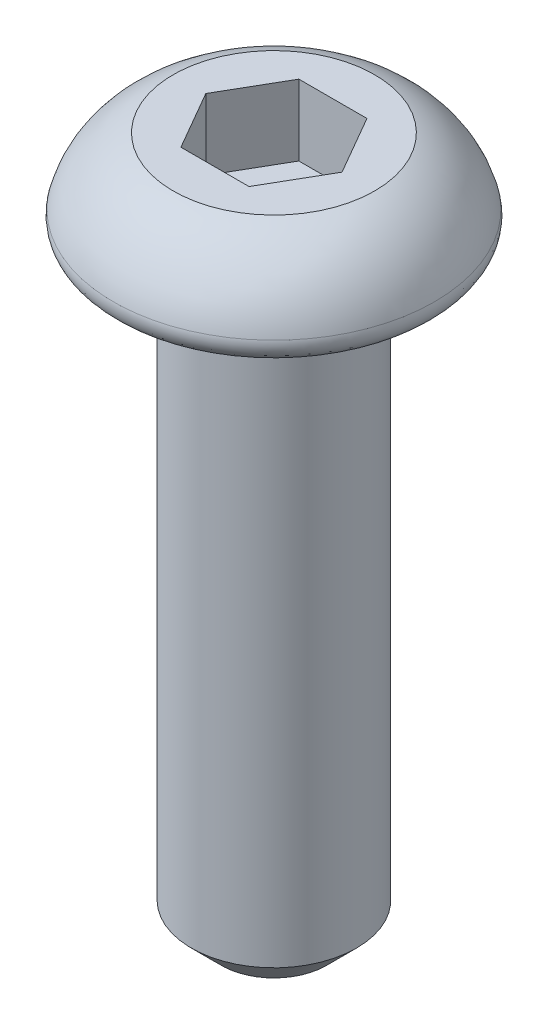
from build123d import *

# Parameters (mm, degrees)
SKETCH2_R           = 1.30175
BOSS_EXTRUDE1_DEPTH = 9.525
CUT_EXTRUDE1_DEPTH  = 1.1176
CHAMFER1_SIZE       = 0.47244
FILLET1_R           = 0.254


with BuildPart() as part:
    # Sketch1 → Revolve1 (revolve)
    with BuildSketch(Plane.XY):
        with BuildLine():
            Line((1.5875, 1.4224), (0, 1.4224))
            Line((0, 1.4224), (0, 0))
            Line((0, 0), (2.235517502, 0))
            add(Edge.make_bspline(
                [(2.530228655, 0.381), (2.538792783, 0.348014811), (2.541780076, 0.313096126), (2.538943152, 0.279135577), (2.536106229, 0.245175028), (2.527366844, 0.211235941), (2.513448709, 0.180128827), (2.499530575, 0.149021713), (2.480049812, 0.119888598), (2.456619631, 0.09514201), (2.433189451, 0.070395421), (2.405163618, 0.049352817), (2.374862966, 0.033756745), (2.344562313, 0.018160672), (2.311151111, 0.007580973), (2.277396156, 0.002893755), (2.263536304, 0.000969174), (2.249510339, 0), (2.235517502, 0)],
                knots=[0, 0, 0, 0, 0.000102237, 0.000102237, 0.000102237, 0.000204473, 0.000204473, 0.000204473, 0.00030671, 0.00030671, 0.00030671, 0.000408946, 0.000408946, 0.000408946, 0.000511183, 0.000511183, 0.000511183, 0.000552664, 0.000552664, 0.000552664, 0.000552664], degree=3))
            ThreePointArc((2.530228655, 0.381), (2.18675257, 1.017470992), (1.5875, 1.4224))
        make_face()
    revolve(axis=Axis((0, 1.4224, 0), (0, -1, 0)))

    # Sketch2 → Boss-Extrude1 (add)
    with BuildSketch(Plane.XZ):
        Circle(SKETCH2_R)
    extrude(amount=BOSS_EXTRUDE1_DEPTH)

    # Sketch3 → Cut-Extrude1 (cut)
    with BuildSketch(Plane(origin=(0, 1.4224, 0), x_dir=(-1, 0, 0), z_dir=(0, 1, 0))):
        Polygon((0.536575, -0.929375162), (1.07315, 0), (0.536575, 0.929375162), (-0.536575, 0.929375162), (-1.07315, 0), (-0.536575, -0.929375162), align=None)
    extrude(amount=-CUT_EXTRUDE1_DEPTH, mode=Mode.SUBTRACT)

    # Chamfer1
    chamfer1_edges = [part.edges().sort_by_distance(p)[0] for p in [
        (-1.30175, -9.525, 0),
    ]]
    chamfer(chamfer1_edges, length=CHAMFER1_SIZE)

    # Fillet1
    fillet1_edges = [part.edges().sort_by_distance(p)[0] for p in [
        (-1.30175, 0, 0),
    ]]
    fillet(fillet1_edges, radius=FILLET1_R)


solid = part.part
